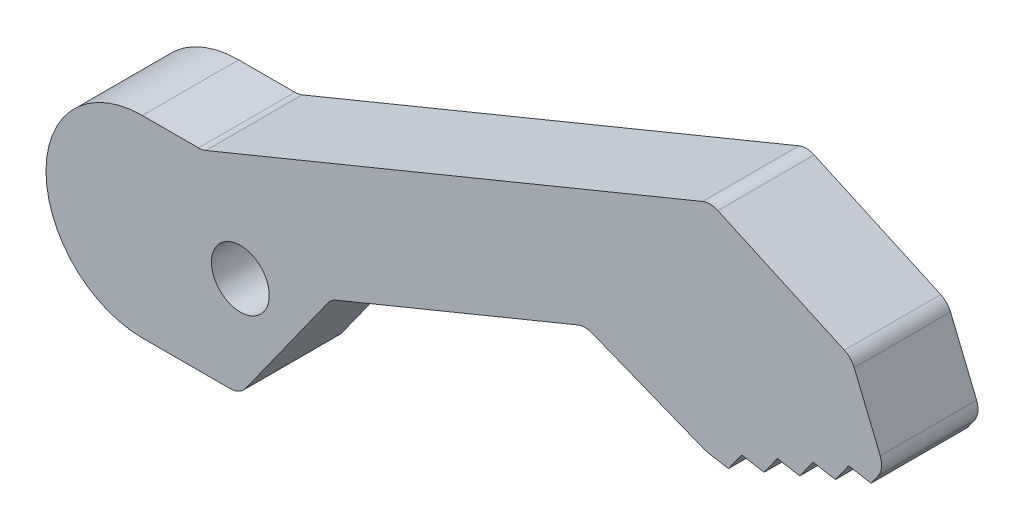
from build123d import *

# Parameters (mm, degrees)
SKETCH1_R           = 1.5
BOSS_EXTRUDE3_DEPTH = 5
FILLET1_R           = 1
CUT_EXTRUDE2_DEPTH  = 5


with BuildPart() as part:
    # Sketch1 → Boss-Extrude3 (new body)
    with BuildSketch(Plane.XY):
        with BuildLine():
            Line((20.05, 5), (0, 5))
            ThreePointArc((0, 5), (-5, 0), (0, -5))
            Line((0, -5), (22, -5))
            Line((22, -5), (26.72989842, 1.621129525))
            Line((26.72989842, 1.621129525), (39.900164389, 7.036080522))
            Line((39.900164389, 7.036080522), (46.188488025, 4.540007042))
            Line((46.188488025, 4.540007042), (47.352932204, 4.337597171))
            Line((47.352932204, 4.337597171), (48.038244482, 5.300533868))
            Line((48.038244482, 5.300533868), (49.20268866, 5.098123997))
            Line((49.20268866, 5.098123997), (49.888000938, 6.061060693))
            Line((49.888000938, 6.061060693), (51.052445116, 5.858650822))
            Line((51.052445116, 5.858650822), (51.737757394, 6.821587519))
            Line((51.737757394, 6.821587519), (52.902201573, 6.619177648))
            Line((52.902201573, 6.619177648), (53.587513851, 7.582114344))
            Line((53.587513851, 7.582114344), (54.751958029, 7.379704473))
            Line((54.751958029, 7.379704473), (55.437270307, 8.34264117))
            Line((55.437270307, 8.34264117), (53.72608495, 12.504593197))
            Line((53.72608495, 12.504593197), (46.409029503, 15.837507263))
            Line((46.409029503, 15.837507263), (20.05, 5))
        make_face()
        Circle(SKETCH1_R, mode=Mode.SUBTRACT)
        with Locations((22.020705275, 0.206842568)):
            Circle(SKETCH1_R, mode=Mode.SUBTRACT)
    extrude(amount=BOSS_EXTRUDE3_DEPTH)

    # Fillet1
    fillet1_edges = [part.edges().sort_by_distance(p)[0] for p in [
        (22, -5, 2.5),
        (20.05, 5, 2.5),
        (46.409029503, 15.837507263, 2.5),
        (53.72608495, 12.504593197, 2.5),
        (55.437270307, 8.34264117, 2.5),
        (46.188488025, 4.540007042, 2.5),
        (39.900164389, 7.036080522, 2.5),
        (26.72989842, 1.621129525, 2.5),
    ]]
    fillet(fillet1_edges, radius=FILLET1_R)

    # Sketch4 → Cut-Extrude2 (cut)
    with BuildSketch(Plane(origin=(0, 0, 0), x_dir=(-1, 0, 0), z_dir=(0, 0, -1))):
        with BuildLine():
            Line((-16.936286021, -5), (9.167349916, -5))
            Line((9.167349916, -5), (9.167349916, 5))
            Line((9.167349916, 5), (-16.936286021, 5))
            ThreePointArc((-16.936286021, 5), (-11.936286021, 0), (-16.936286021, -5))
        make_face()
    extrude(amount=-CUT_EXTRUDE2_DEPTH, mode=Mode.SUBTRACT)


solid = part.part
